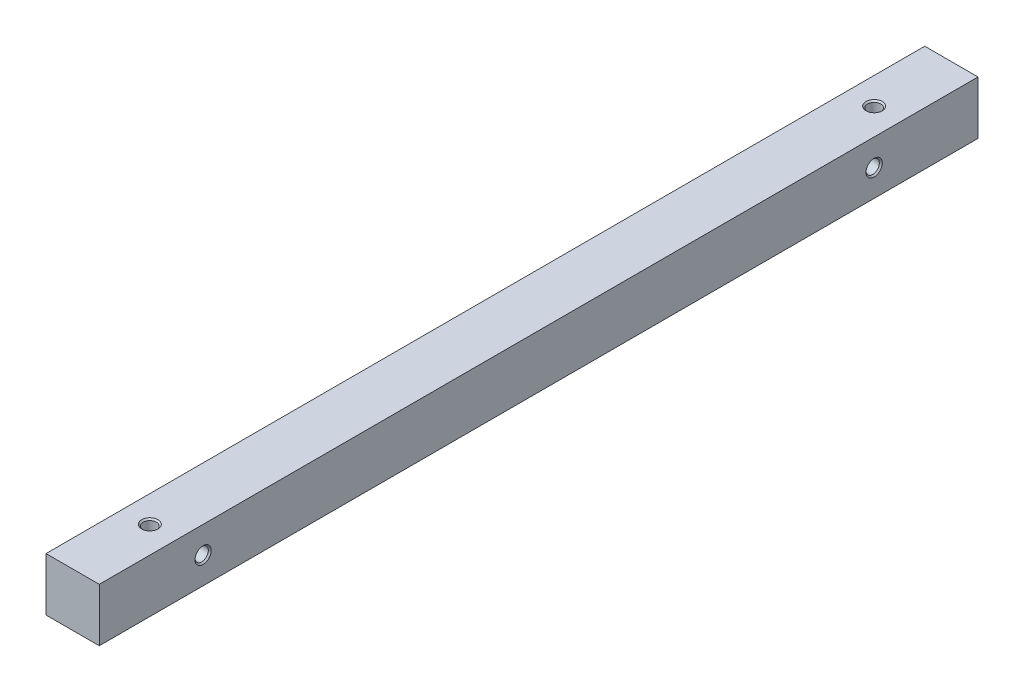
from build123d import *

# Parameters (mm, degrees)
ESQUISSE1_W                     = 10
ESQUISSE1_H                     = 10
BOSS_EXTRU_1_DEPTH              = 82.5
TROU_TARAUD_M3X0_51_D           = 2.5
TROU_TARAUD_M3X0_51_CSINK_D     = 3.05
TROU_TARAUD_M3X0_51_CSINK_ANGLE = 90
TROU_TARAUD_M3X0_52_D           = 2.5
TROU_TARAUD_M3X0_52_CSINK_D     = 3.05
TROU_TARAUD_M3X0_52_CSINK_ANGLE = 90


with BuildPart() as part:
    # Esquisse1 → Boss.-Extru.1 (new body, symmetric)
    with BuildSketch(Plane.XY):
        Rectangle(ESQUISSE1_W, ESQUISSE1_H)
    extrude(amount=BOSS_EXTRU_1_DEPTH, both=True)

    # Trou taraudé M3x0.51 (through all)
    with Locations(Plane(origin=(5, 0, 0), x_dir=(0, 0, -1), z_dir=(1, 0, 0))):
        with Locations((63, 0), (-63, 0)):
            CounterSinkHole(TROU_TARAUD_M3X0_51_D / 2, TROU_TARAUD_M3X0_51_CSINK_D / 2, counter_sink_angle=TROU_TARAUD_M3X0_51_CSINK_ANGLE)

    # Trou taraudé M3x0.52 (through all)
    with Locations(Plane(origin=(0, 5, 0), x_dir=(1, 0, 0), z_dir=(0, 1, 0))):
        with Locations((0, 68), (0, -68)):
            CounterSinkHole(TROU_TARAUD_M3X0_52_D / 2, TROU_TARAUD_M3X0_52_CSINK_D / 2, counter_sink_angle=TROU_TARAUD_M3X0_52_CSINK_ANGLE)


solid = part.part
